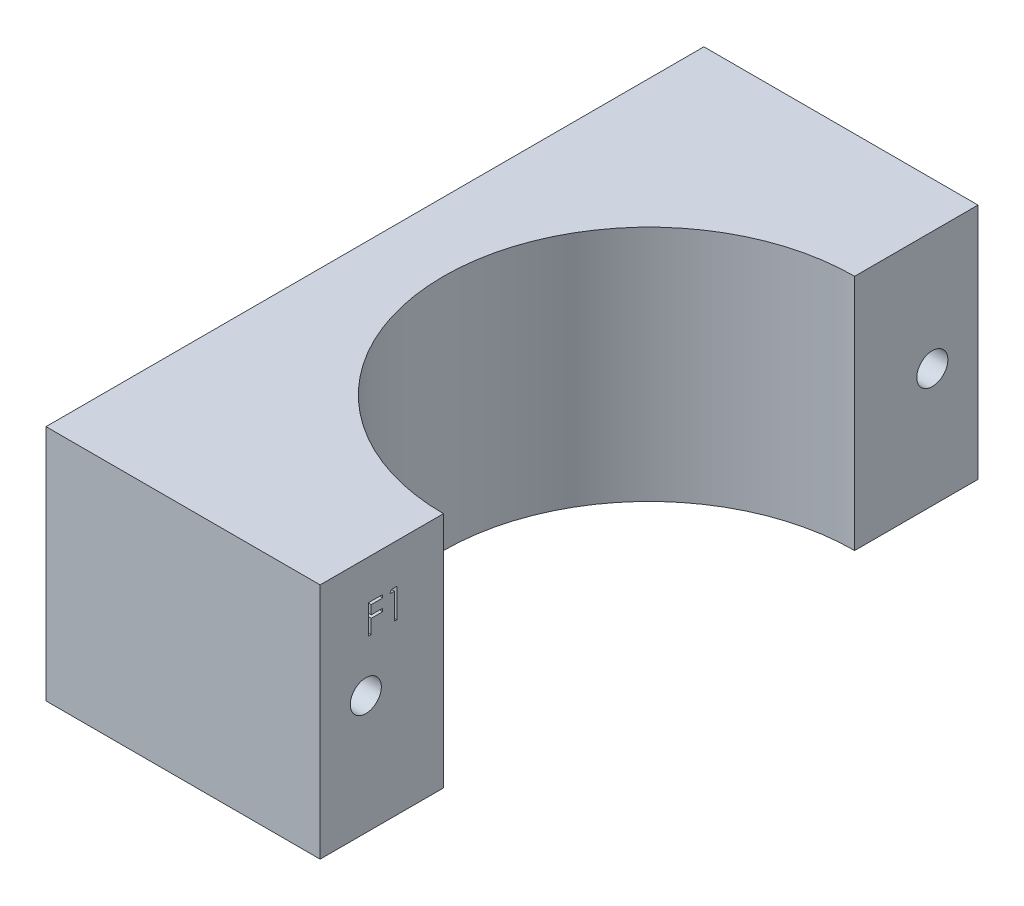
from build123d import *

# Parameters (mm, degrees)
BOSS_EXTRUDE1_DEPTH = 26
SKETCH2_R           = 1.7
CUT_EXTRUDE1_DEPTH  = 31
CUT_EXTRUDE2_DEPTH  = 1


with BuildPart() as part:
    # Sketch1 → Boss-Extrude1 (new body)
    with BuildSketch(Plane(origin=(0, 0, 0), x_dir=(1, 0, 0), z_dir=(0, 1, 0))):
        with BuildLine():
            Line((-46.998275301, 32.528571429), (-46.998275301, -39.471428571))
            Line((-46.998275301, -39.471428571), (-16.998275301, -39.471428571))
            Line((-16.998275301, -39.471428571), (-16.998275301, -25.971428571))
            ThreePointArc((-16.998275301, -25.971428571), (-39.498275301, -3.471428571), (-16.998275301, 19.028571429))
            Line((-16.998275301, 19.028571429), (-16.998275301, 32.528571429))
            Line((-16.998275301, 32.528571429), (-46.998275301, 32.528571429))
        make_face()
    extrude(amount=BOSS_EXTRUDE1_DEPTH)

    # Sketch2 → Cut-Extrude1 (cut, through all)
    with BuildSketch(Plane(origin=(-16.998275301, 0, 0), x_dir=(0, 0, -1), z_dir=(1, 0, 0))):
        with Locations((-34.471428571, 13)):
            Circle(SKETCH2_R)
        with Locations((27.528571429, 13)):
            Circle(SKETCH2_R)
    extrude(amount=-CUT_EXTRUDE1_DEPTH, mode=Mode.SUBTRACT)

    # Sketch3 → Cut-Extrude2 (cut)
    with BuildSketch(Plane(origin=(-16.998275301, 0, 0), x_dir=(0, 0, -1), z_dir=(1, 0, 0))):
        Polygon((-34.164231178, 21.664809495), (-32.617436306, 21.664809495), (-32.617436306, 21.33916847), (-33.87929528, 21.33916847), (-33.87929528, 20.362245393), (-32.617436306, 20.362245393), (-32.617436306, 20.036604367), (-33.87929528, 20.036604367), (-33.87929528, 18.489809495), (-34.164231178, 18.489809495), align=None)
        Polygon((-31.657685705, 21.664809495), (-31.070641434, 21.664809495), (-31.070641434, 18.489809495), (-31.355577332, 18.489809495), (-31.355577332, 21.33916847), (-31.84403887, 21.33916847), align=None)
    extrude(amount=-CUT_EXTRUDE2_DEPTH, mode=Mode.SUBTRACT)


solid = part.part
